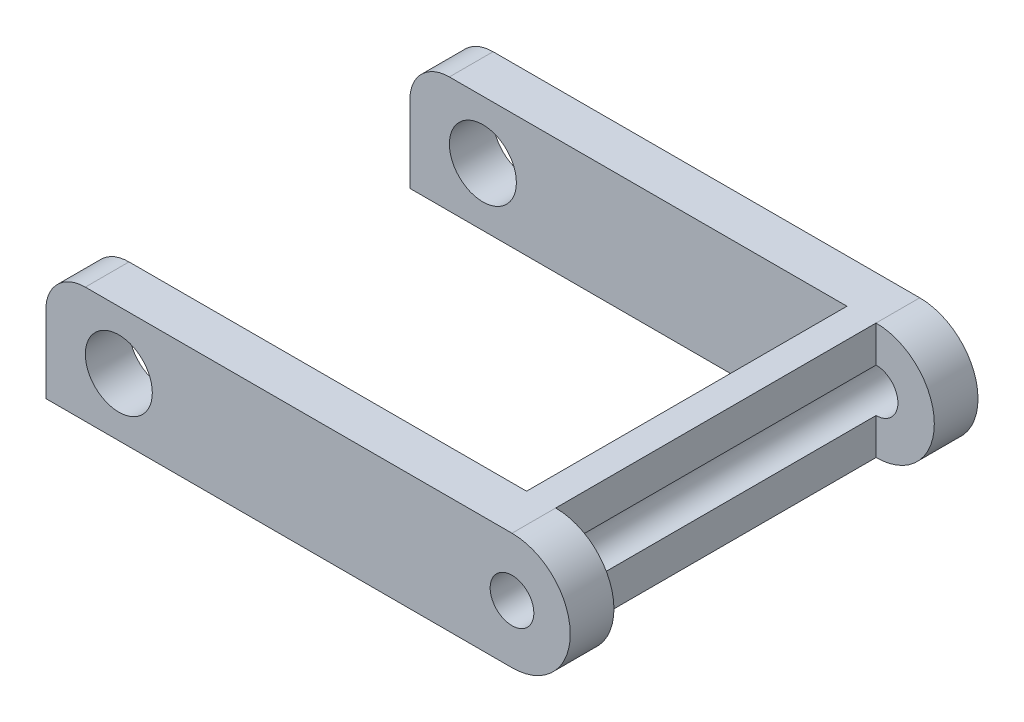
from build123d import *

# Parameters (mm, degrees)
SKETCH5_R          = 1.15
SKETCH5_R_2        = 0.749999784
BASE_EXTRUDE_DEPTH = 14.000000432
SKETCH9_OUTSIDE_W  = 24.639
SKETCH9_OUTSIDE_H  = 20.632
CUT_EXTRUDE2_DEPTH = 37.000000432


with BuildPart() as part:
    # Sketch5 → Base-Extrude (new body)
    with BuildSketch(Plane.XY):
        with BuildLine():
            Line((-14.650000216, 1.992481203), (-2.16e-07, 2.000000047))
            ThreePointArc((-2.16e-07, 2.000000047), (2.000000047, 1.08e-07), (0, -2.000000047))
            Line((0, -2.000000047), (-15.999999829, -2.000000047))
            Line((-15.999999829, -2.000000047), (-15.999999829, 0.500000071))
            ThreePointArc((-15.999999829, 0.500000071), (-15.656001468, 1.545642629), (-14.650000216, 1.992481203))
        make_face()
        with Locations((-13.500000216, 4.7e-08)):
            Circle(SKETCH5_R, mode=Mode.SUBTRACT)
        Circle(SKETCH5_R_2, mode=Mode.SUBTRACT)
    extrude(amount=-BASE_EXTRUDE_DEPTH)

    # Sketch9 outside → Cut-Extrude2 (cut)
    with BuildSketch(Plane(origin=(0, 17.539650086, 0), x_dir=(-1, 0, 0), z_dir=(0, 1, 0))):
        with Locations((7.0035, -7)):
            Rectangle(SKETCH9_OUTSIDE_W, SKETCH9_OUTSIDE_H)
        Polygon((5.500000203, -12.500000186), (15.999999829, -12.500000186), (15.999999829, -14.000000432), (-1.999999397, -14.000000432), (-1.999999397, -12.500000186), (0, -12.500000186), (0, -1.500000246), (-1.999999397, -1.500000246), (-1.999999397, 0), (15.999999829, 0), (15.999999829, -1.500000246), (5.500000203, -1.500000246), (1.000000164, -1.500000246), (1.000000164, -12.500000186), align=None, mode=Mode.SUBTRACT)
    extrude(amount=-CUT_EXTRUDE2_DEPTH, mode=Mode.SUBTRACT)


solid = part.part
